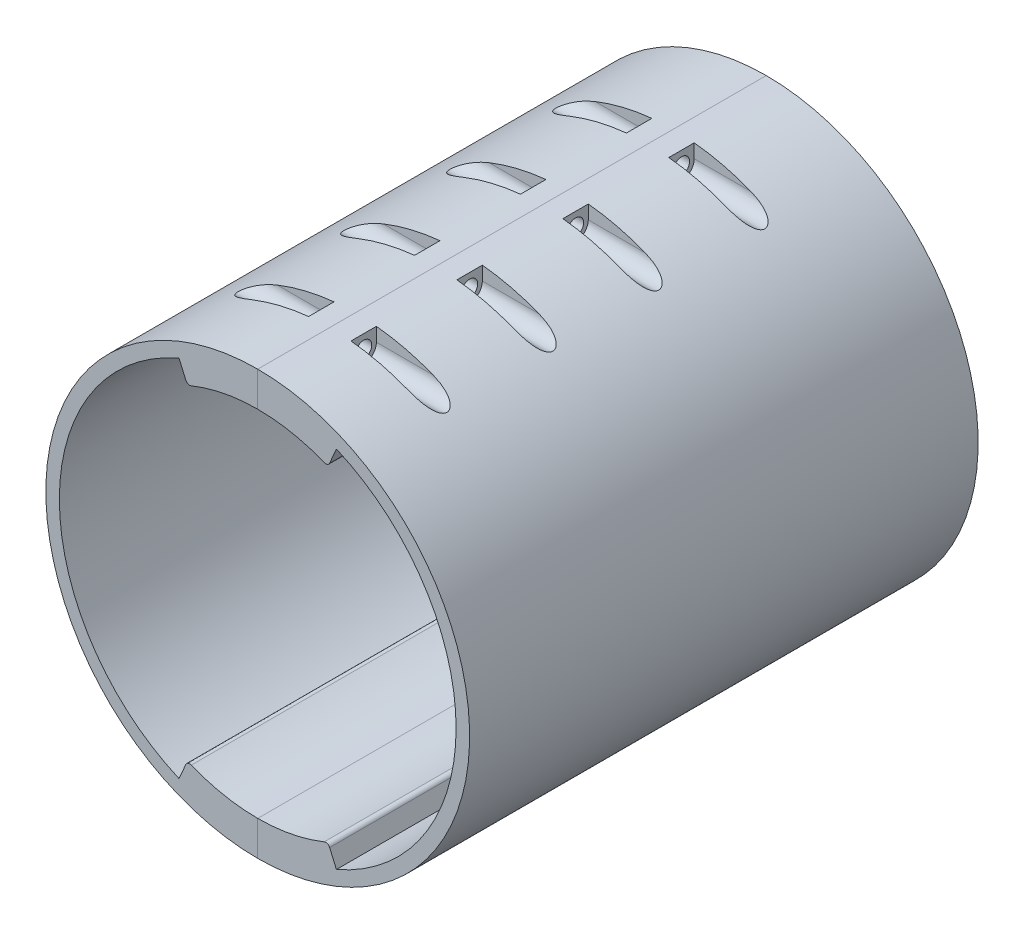
from build123d import *

# Parameters (mm, degrees)
SKETCH1_W                      = 300
SKETCH1_H                      = 170
BOSS_EXTRUDE1_DEPTH            = 225
SHELL1_T                       = -10
SKETCH2_R                      = 6.5
CUT_EXTRUDE1_DEPTH             = 10
CIRPATTERN1_COUNT              = 4
SKETCH6_OUTSIDE_W              = 384.346
SKETCH6_OUTSIDE_H              = 309.346
SKETCH6_OUTSIDE_R              = 100
CUT_EXTRUDE2_DEPTH             = 171
SKETCH7_R                      = 100
SKETCH7_R_2                    = 93.619049124
BOSS_EXTRUDE2_DEPTH            = 200
SKETCH8_R                      = 100
SKETCH8_R_2                    = 95
BOSS_EXTRUDE3_DEPTH            = 30
SKETCH11_R                     = 95
SKETCH11_R_2                   = 90
BOSS_EXTRUDE4_DEPTH            = 30
CUT_EXTRUDE3_DEPTH             = 47
BOSS_EXTRUDE6_REACH            = 242
FILLET2_R                      = 2
CUT_EXTRUDE4_DEPTH             = 35
CUT_EXTRUDE5_DEPTH             = 35
M7_CLEARANCE_HOLE1_D           = 7.6
M7_CLEARANCE_HOLE1_CSINK_D     = 7.65
M7_CLEARANCE_HOLE1_CSINK_ANGLE = 90


with BuildPart() as part:
    # Sketch1 → Boss-Extrude1 (new body)
    with BuildSketch(Plane(origin=(0, 0, 0), x_dir=(1, 0, 0), z_dir=(0, 1, 0))):
        with Locations((-150, -85)):
            Rectangle(SKETCH1_W, SKETCH1_H)
    extrude(amount=BOSS_EXTRUDE1_DEPTH)

    # Shell1
    shell1_openings = [part.faces().sort_by_distance(p)[0] for p in [
        (-150, 112.5, 170),
    ]]
    offset(amount=SHELL1_T, openings=shell1_openings, kind=Kind.INTERSECTION)

    # Sketch2 → Cut-Extrude1 (cut)
    with BuildSketch(Plane.XY.offset(10)):
        with Locations((-150, 112.5)):
            Circle(SKETCH2_R)
    extrude(amount=-CUT_EXTRUDE1_DEPTH, mode=Mode.SUBTRACT)

    # Sketch5 → M5 Clearance Hole1 (revolve, cut)
    with BuildSketch(Plane(origin=(-134.090097423, 128.409902577, 10), x_dir=(0, -1, 0), z_dir=(1, 0, 0))):
        Polygon((0, 0), (0, 21.652366702), (2.75, 20), (2.75, 0.025), (2.775, 0), align=None)
    m5_clearance_hole1 = revolve(axis=Axis((-134.090097423, 128.409902577, 16.35), (0, 0, -1)), mode=Mode.SUBTRACT)

    # CirPattern1: M5 Clearance Hole1 ×4 about axis
    cirpattern1_axis = Axis((-150, 112.5, 0), (0, 0, 1))
    for i in range(1, CIRPATTERN1_COUNT):
        add(m5_clearance_hole1.rotate(cirpattern1_axis, i * 360 / CIRPATTERN1_COUNT), mode=Mode.SUBTRACT)

    # Sketch6 outside → Cut-Extrude2 (cut, through all)
    with BuildSketch(Plane(origin=(0, 0, 0), x_dir=(-1, 0, 0), z_dir=(0, 0, -1))):
        with Locations((150, 112.5)):
            Rectangle(SKETCH6_OUTSIDE_W, SKETCH6_OUTSIDE_H)
        with Locations((150, 112.5)):
            Circle(SKETCH6_OUTSIDE_R, mode=Mode.SUBTRACT)
    extrude(amount=-CUT_EXTRUDE2_DEPTH, mode=Mode.SUBTRACT)

    # Sketch7 → Boss-Extrude2 (add)
    with BuildSketch(Plane.XY.offset(10)):
        with Locations((-150, 112.5)):
            Circle(SKETCH7_R)
        with Locations((-150, 112.5)):
            Circle(SKETCH7_R_2, mode=Mode.SUBTRACT)
    extrude(amount=BOSS_EXTRUDE2_DEPTH)

    # Sketch8 → Boss-Extrude3 (add)
    with BuildSketch(Plane(origin=(0, 0, 0), x_dir=(-1, 0, 0), z_dir=(0, 0, -1))):
        with Locations((150, 112.5)):
            Circle(SKETCH8_R)
        with Locations((150, 112.5)):
            Circle(SKETCH8_R_2, mode=Mode.SUBTRACT)
    extrude(amount=BOSS_EXTRUDE3_DEPTH)

    # Sketch11 → Boss-Extrude4 (add)
    with BuildSketch(Plane(origin=(0, 0, 0), x_dir=(-1, 0, 0), z_dir=(0, 0, -1))):
        with Locations((150, 112.5)):
            Circle(SKETCH11_R)
        with Locations((150, 112.5)):
            Circle(SKETCH11_R_2, mode=Mode.SUBTRACT)
    extrude(amount=BOSS_EXTRUDE4_DEPTH)

    # Sketch13 → Cut-Extrude3 (cut)
    with BuildSketch(Plane(origin=(-140, 0, 0), x_dir=(0, 0, -1), z_dir=(1, 0, 0))):
        with BuildLine():
            Line((-176, 212.5), (-176, 205.5))
            ThreePointArc((-176, 205.5), (-170, 199.5), (-164, 205.5))
            Line((-164, 205.5), (-164, 212.5))
            Line((-164, 212.5), (-176, 212.5))
        make_face()
        with BuildLine():
            Line((-26, 212.5), (-26, 205.5))
            ThreePointArc((-26, 205.5), (-20, 199.5), (-14, 205.5))
            Line((-14, 205.5), (-14, 212.5))
            Line((-14, 212.5), (-26, 212.5))
        make_face()
        with BuildLine():
            Line((-76, 212.5), (-76, 205.5))
            ThreePointArc((-76, 205.5), (-70, 199.5), (-64, 205.5))
            Line((-64, 205.5), (-64, 212.5))
            Line((-64, 212.5), (-76, 212.5))
        make_face()
        with BuildLine():
            Line((-114, 212.5), (-126, 212.5))
            Line((-126, 212.5), (-126, 205.5))
            ThreePointArc((-126, 205.5), (-120, 199.5), (-114, 205.5))
            Line((-114, 205.5), (-114, 212.5))
        make_face()
        with BuildLine():
            Line((-114, 12.5), (-114, 19.5))
            ThreePointArc((-114, 19.5), (-120, 25.5), (-126, 19.5))
            Line((-126, 19.5), (-126, 12.5))
            Line((-126, 12.5), (-114, 12.5))
        make_face()
        with BuildLine():
            Line((-64, 12.5), (-64, 19.5))
            ThreePointArc((-64, 19.5), (-70, 25.5), (-76, 19.5))
            Line((-76, 19.5), (-76, 12.5))
            Line((-76, 12.5), (-64, 12.5))
        make_face()
        with BuildLine():
            Line((-14, 12.5), (-14, 19.5))
            ThreePointArc((-14, 19.5), (-20, 25.5), (-26, 19.5))
            Line((-26, 19.5), (-26, 12.5))
            Line((-26, 12.5), (-14, 12.5))
        make_face()
        with BuildLine():
            Line((-176, 12.5), (-164, 12.5))
            Line((-164, 12.5), (-164, 19.5))
            ThreePointArc((-164, 19.5), (-170, 25.5), (-176, 19.5))
            Line((-176, 19.5), (-176, 12.5))
        make_face()
    cut_extrude3 = extrude(amount=CUT_EXTRUDE3_DEPTH, mode=Mode.SUBTRACT)

    # Mirror1: Cut-Extrude3 across plane
    add(cut_extrude3.mirror(Plane(origin=(-150, 0, 0), x_dir=(0, 0, 1), z_dir=(1, 0, 0))), mode=Mode.SUBTRACT)

    # Sketch15 → Boss-Extrude6 (add, up to next)
    with BuildSketch(Plane.XY.offset(210), mode=Mode.PRIVATE) as boss_extrude6_sk1:
        with BuildLine():
            Line((-187.135445002, 198.438845021), (-183.168790208, 189.259212689))
            ThreePointArc((-183.168790208, 189.259212689), (-150, 196.119049124), (-116.831209792, 189.259212689))
            Line((-116.831209792, 189.259212689), (-112.864554998, 198.438845021))
            ThreePointArc((-112.864554998, 198.438845021), (-150, 206.119049124), (-187.135445002, 198.438845021))
        make_face()
    boss_extrude6_tool1 = extrude(boss_extrude6_sk1.sketch, amount=-BOSS_EXTRUDE6_REACH, mode=Mode.PRIVATE) - part.part
    add(boss_extrude6_tool1.solids().sort_by_distance((-150, 198.77364, 210))[0])
    # Sketch15 → Boss-Extrude6 (add, up to next)
    with BuildSketch(Plane.XY.offset(210), mode=Mode.PRIVATE) as boss_extrude6_sk2:
        with BuildLine():
            Line((-112.864554998, 26.561154979), (-116.831209792, 35.740787311))
            ThreePointArc((-116.831209792, 35.740787311), (-150, 28.880950876), (-183.168790208, 35.740787311))
            Line((-183.168790208, 35.740787311), (-187.135445002, 26.561154979))
            ThreePointArc((-187.135445002, 26.561154979), (-150, 18.880950876), (-112.864554998, 26.561154979))
        make_face()
    boss_extrude6_tool2 = extrude(boss_extrude6_sk2.sketch, amount=-BOSS_EXTRUDE6_REACH, mode=Mode.PRIVATE) - part.part
    add(boss_extrude6_tool2.solids().sort_by_distance((-150, 26.22636, 210))[0])

    # Fillet2
    fillet2_edges = [part.edges().sort_by_distance(p)[0] for p in [
        (-116.831209792, 189.259212689, 110),
        (-183.168790208, 189.259212689, 110),
        (-116.831209792, 35.740787311, 110),
        (-183.168790208, 35.740787311, 110),
    ]]
    fillet(fillet2_edges, radius=FILLET2_R)

    # Sketch16 → Cut-Extrude4 (cut)
    with BuildSketch(Plane(origin=(-140, 0, 0), x_dir=(0, 0, -1), z_dir=(1, 0, 0))):
        with BuildLine():
            Line((-76, 212.5), (-76, 205.5))
            ThreePointArc((-76, 205.5), (-70, 199.5), (-64, 205.5))
            Line((-64, 205.5), (-64, 212.5))
            Line((-64, 212.5), (-76, 212.5))
        make_face()
        with BuildLine():
            Line((-26, 212.5), (-26, 205.5))
            ThreePointArc((-26, 205.5), (-20, 199.5), (-14, 205.5))
            Line((-14, 205.5), (-14, 212.5))
            Line((-14, 212.5), (-26, 212.5))
        make_face()
        with BuildLine():
            Line((-176, 212.5), (-176, 205.5))
            ThreePointArc((-176, 205.5), (-170, 199.5), (-164, 205.5))
            Line((-164, 205.5), (-164, 212.5))
            Line((-164, 212.5), (-176, 212.5))
        make_face()
        with BuildLine():
            Line((-64, 12.5), (-64, 19.5))
            ThreePointArc((-64, 19.5), (-70, 25.5), (-76, 19.5))
            Line((-76, 19.5), (-76, 12.5))
            Line((-76, 12.5), (-64, 12.5))
        make_face()
        with BuildLine():
            Line((-114, 12.5), (-114, 19.5))
            ThreePointArc((-114, 19.5), (-120, 25.5), (-126, 19.5))
            Line((-126, 19.5), (-126, 12.5))
            Line((-126, 12.5), (-114, 12.5))
        make_face()
        with BuildLine():
            Line((-114, 212.5), (-126, 212.5))
            Line((-126, 212.5), (-126, 205.5))
            ThreePointArc((-126, 205.5), (-120, 199.5), (-114, 205.5))
            Line((-114, 205.5), (-114, 212.5))
        make_face()
        with BuildLine():
            Line((-176, 12.5), (-164, 12.5))
            Line((-164, 12.5), (-164, 19.5))
            ThreePointArc((-164, 19.5), (-170, 25.5), (-176, 19.5))
            Line((-176, 19.5), (-176, 12.5))
        make_face()
        with BuildLine():
            Line((-26, 19.5), (-26, 12.5))
            Line((-26, 12.5), (-14, 12.5))
            Line((-14, 12.5), (-14, 19.5))
            ThreePointArc((-14, 19.5), (-20, 25.5), (-26, 19.5))
        make_face()
    extrude(amount=CUT_EXTRUDE4_DEPTH, mode=Mode.SUBTRACT)

    # Sketch17 → Cut-Extrude5 (cut)
    with BuildSketch(Plane.ZY.offset(160)):
        with BuildLine():
            Line((76, 205.5), (76, 212.5))
            Line((76, 212.5), (64, 212.5))
            Line((64, 212.5), (64, 205.5))
            ThreePointArc((64, 205.5), (70, 199.5), (76, 205.5))
        make_face()
        with BuildLine():
            Line((26, 205.5), (26, 212.5))
            Line((26, 212.5), (14, 212.5))
            Line((14, 212.5), (14, 205.5))
            ThreePointArc((14, 205.5), (20, 199.5), (26, 205.5))
        make_face()
        with BuildLine():
            Line((176, 205.5), (176, 212.5))
            Line((176, 212.5), (164, 212.5))
            Line((164, 212.5), (164, 205.5))
            ThreePointArc((164, 205.5), (170, 199.5), (176, 205.5))
        make_face()
        with BuildLine():
            Line((64, 19.5), (64, 12.5))
            Line((64, 12.5), (76, 12.5))
            Line((76, 12.5), (76, 19.5))
            ThreePointArc((76, 19.5), (70, 25.5), (64, 19.5))
        make_face()
        with BuildLine():
            Line((114, 19.5), (114, 12.5))
            Line((114, 12.5), (126, 12.5))
            Line((126, 12.5), (126, 19.5))
            ThreePointArc((126, 19.5), (120, 25.5), (114, 19.5))
        make_face()
        with BuildLine():
            Line((126, 212.5), (114, 212.5))
            Line((114, 212.5), (114, 205.5))
            ThreePointArc((114, 205.5), (120, 199.5), (126, 205.5))
            Line((126, 205.5), (126, 212.5))
        make_face()
        with BuildLine():
            Line((164, 12.5), (176, 12.5))
            Line((176, 12.5), (176, 19.5))
            ThreePointArc((176, 19.5), (170, 25.5), (164, 19.5))
            Line((164, 19.5), (164, 12.5))
        make_face()
        with BuildLine():
            Line((26, 12.5), (26, 19.5))
            ThreePointArc((26, 19.5), (20, 25.5), (14, 19.5))
            Line((14, 19.5), (14, 12.5))
            Line((14, 12.5), (26, 12.5))
        make_face()
    extrude(amount=CUT_EXTRUDE5_DEPTH, mode=Mode.SUBTRACT)

    # M7 Clearance Hole1 (through all)
    with Locations(Plane(origin=(-160, 205.5, 20), x_dir=(0, 0, -1), z_dir=(-1, 0, 0))):
        with Locations((0, 0), (-50, 0), (-100, 0), (0, 186), (-50, 186), (-100, 186), (-150, 186), (-150, 0)):
            CounterSinkHole(M7_CLEARANCE_HOLE1_D / 2, M7_CLEARANCE_HOLE1_CSINK_D / 2, counter_sink_angle=M7_CLEARANCE_HOLE1_CSINK_ANGLE)


with BuildPart() as body_2:
    # Split1: the piece on the far side of the plane
    add(part.part)
    split(bisect_by=Plane(origin=(-150, 0, 0), x_dir=(0, 0, 1), z_dir=(1, 0, 0)), keep=Keep.BOTTOM)


with BuildPart() as part_1:
    add(part.part)

    # Split1
    split(bisect_by=Plane(origin=(-150, 0, 0), x_dir=(0, 0, 1), z_dir=(1, 0, 0)), keep=Keep.TOP)


solid = Compound([body_2.part, part_1.part])
